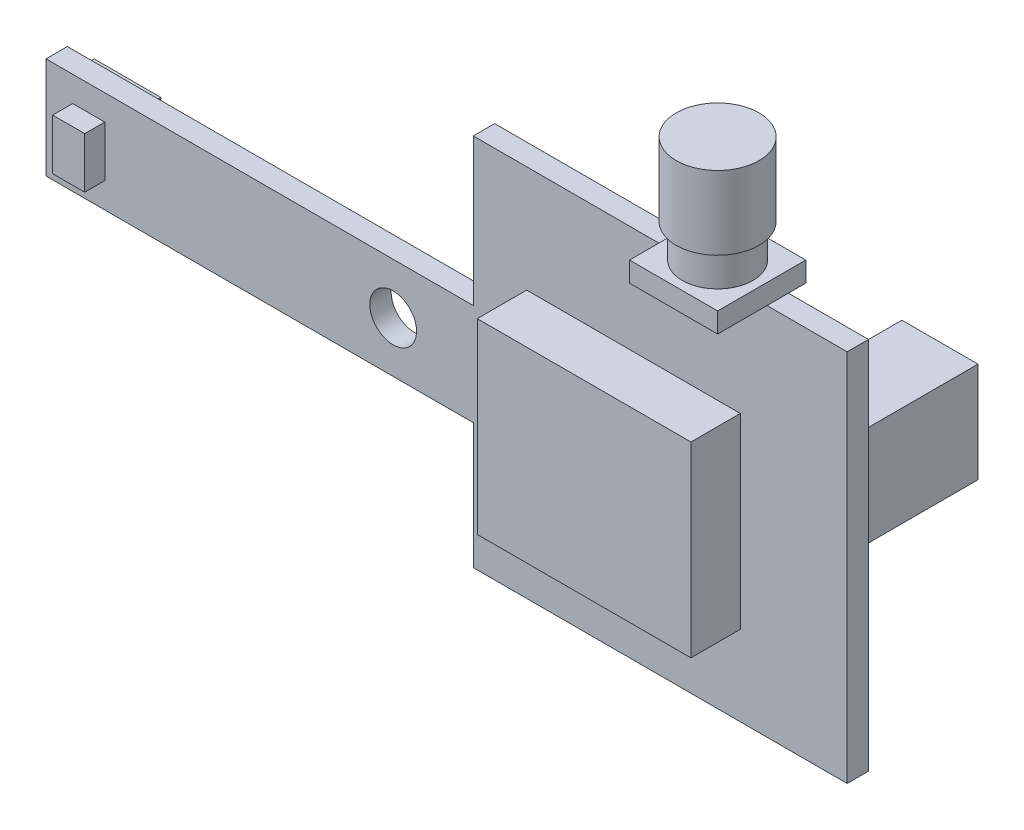
from build123d import *

# Parameters (mm, degrees)
SKETCH1_W             = 28
SKETCH1_H             = 28
SKETCH1_W_2           = 32
SKETCH1_H_2           = 7.6
SKETCH1_R             = 1.75
BOSS_EXTRUDE1_DEPTH   = 1.6
SKETCH2_W             = 6.6
SKETCH2_H             = 6.6
BOSS_EXTRUDE2_DEPTH   = 1.5
SKETCH3_R             = 2.65
BOSS_EXTRUDE3_DEPTH   = 2.5
SKETCH4_R             = 3.1
BOSS_EXTRUDE4_DEPTH   = 5.5
SKETCH5_W             = 16
SKETCH5_H             = 14
BOSS_EXTRUDE5_DEPTH   = 3.7
SKETCH6_W             = 2.4
SKETCH6_H             = 3.8
BOSS_EXTRUDE6_DEPTH   = 1.5
SKETCH7_W             = 5.7
SKETCH7_H             = 7.5
BOSS_EXTRUDE7_DEPTH   = 1.5
SKETCH7_W_2           = 7.3
SKETCH7_H_2           = 6.8
BOSS_EXTRUDE7_2_DEPTH = 1.5
SKETCH7_W_3           = 5
SKETCH7_H_3           = 5
BOSS_EXTRUDE7_3_DEPTH = 1.5
MOVE_FACE2_BY         = 8


with BuildPart() as part:
    # Sketch1 → Boss-Extrude1 (new body)
    with BuildSketch(Plane.XY):
        with Locations((14, 0.8)):
            Rectangle(SKETCH1_W, SKETCH1_H)
        with Locations((-16, 0)):
            Rectangle(SKETCH1_W_2, SKETCH1_H_2)
        with Locations((-6, 0)):
            Circle(SKETCH1_R, mode=Mode.SUBTRACT)
    extrude(amount=BOSS_EXTRUDE1_DEPTH)


with BuildPart() as body_2:
    # Sketch2 → Boss-Extrude2 (new body)
    with BuildSketch(Plane(origin=(0, 14.8, 0), x_dir=(1, 0, 0), z_dir=(0, 1, 0))):
        with Locations((18.7, -2)):
            Rectangle(SKETCH2_W, SKETCH2_H)
    extrude(amount=BOSS_EXTRUDE2_DEPTH)

    # Sketch3 → Boss-Extrude3 (add)
    with BuildSketch(Plane(origin=(0, 16.3, 0), x_dir=(1, 0, 0), z_dir=(0, 1, 0))):
        with Locations(Location((18.7, -2, 0), (0, 0, 270))):
            Circle(SKETCH3_R)
    extrude(amount=BOSS_EXTRUDE3_DEPTH)

    # Sketch4 → Boss-Extrude4 (add)
    with BuildSketch(Plane(origin=(0, 18.8, 0), x_dir=(1, 0, 0), z_dir=(0, 1, 0))):
        with Locations(Location((18.7, -2, 0), (0, 0, 270))):
            Circle(SKETCH4_R)
    extrude(amount=BOSS_EXTRUDE4_DEPTH)


with BuildPart() as body_3:
    # Sketch5 → Boss-Extrude5 (new body)
    with BuildSketch(Plane.XY.offset(1.6)):
        with Locations((12, -0.2)):
            Rectangle(SKETCH5_W, SKETCH5_H)
    extrude(amount=BOSS_EXTRUDE5_DEPTH)


with BuildPart() as body_4:
    # Sketch6 → Boss-Extrude6 (new body)
    with BuildSketch(Plane.XY.offset(1.6)):
        with Locations((-28.8, 0)):
            Rectangle(SKETCH6_W, SKETCH6_H)
    extrude(amount=BOSS_EXTRUDE6_DEPTH)


with BuildPart() as body_5:
    # Sketch7 → Boss-Extrude7 (new body)
    with BuildSketch(Plane(origin=(0, 0, 0), x_dir=(-1, 0, 0), z_dir=(0, 0, -1))):
        with Locations((-23.85, 4.05)):
            Rectangle(SKETCH7_W, SKETCH7_H)
    extrude(amount=BOSS_EXTRUDE7_DEPTH)

    # Move Face2: a face moved outward by 8.0
    extrude(body_5.faces().sort_by_distance((23.85, 4.05, -1.5))[0], amount=MOVE_FACE2_BY, dir=(0, 0, -1))


with BuildPart() as body_6:
    # Sketch7 → Boss-Extrude7 2 (new body)
    with BuildSketch(Plane(origin=(0, 0, 0), x_dir=(-1, 0, 0), z_dir=(0, 0, -1))):
        with Locations((-9.05, 0.2)):
            Rectangle(SKETCH7_W_2, SKETCH7_H_2)
    extrude(amount=BOSS_EXTRUDE7_2_DEPTH)


with BuildPart() as body_7:
    # Sketch7 → Boss-Extrude7 3 (new body)
    with BuildSketch(Plane(origin=(0, 0, 0), x_dir=(-1, 0, 0), z_dir=(0, 0, -1))):
        with Locations((29, 0)):
            Rectangle(SKETCH7_W_3, SKETCH7_H_3)
    extrude(amount=BOSS_EXTRUDE7_3_DEPTH)


solid = Compound([part.part, body_2.part, body_3.part, body_4.part, body_5.part, body_6.part, body_7.part])
